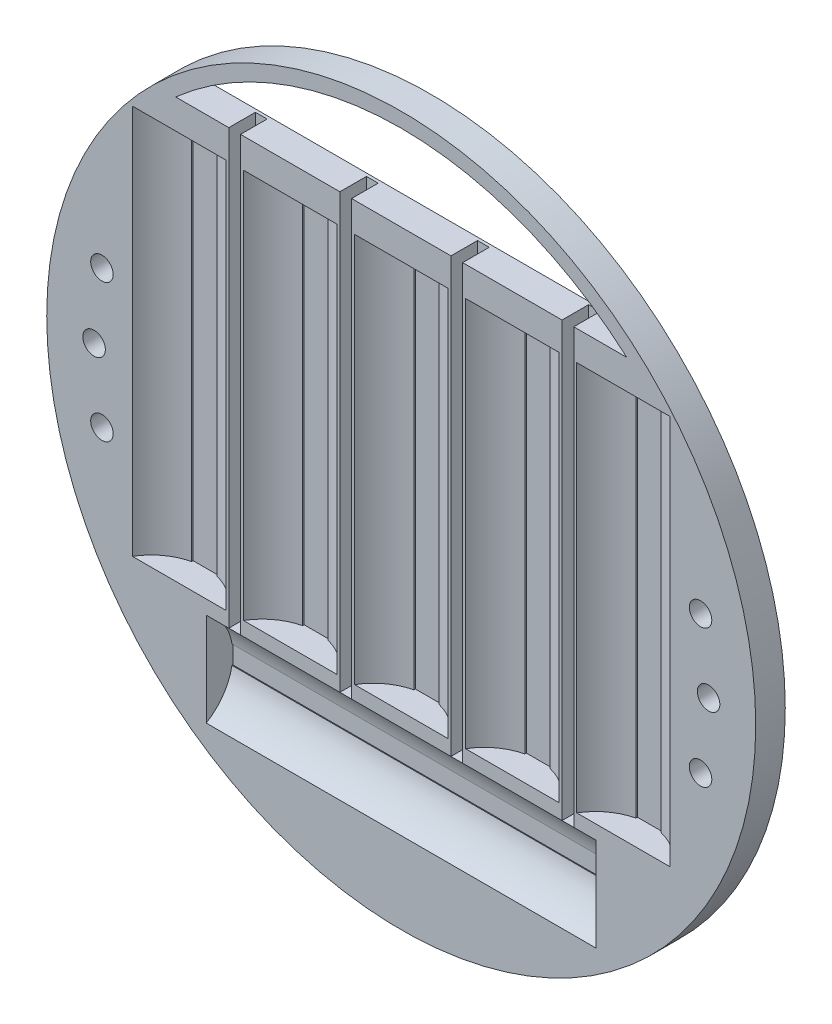
from build123d import *

# Parameters (mm, degrees)
SKETCH1_R               = 60
BOSS_EXTRUDE1_DEPTH     = 5
SKETCH2_W               = 92
SKETCH2_H               = 66
CUT_EXTRUDE1_DEPTH      = 4.5
SKETCH3_W               = 66
SKETCH3_H               = 18.4
CUT_EXTRUDE2_DEPTH      = 4.5
CUT_EXTRUDE3_DEPTH      = 5.5
CUT_EXTRUDE3_DEPTH_BACK = 1.5
BOSS_EXTRUDE4_DEPTH     = 66
BOSS_EXTRUDE5_DEPTH     = 66
LPATTERN1_COUNT         = 5
LPATTERN1_PITCH         = 18.8
SKETCH10_R              = 1.905
CUT_EXTRUDE4_DEPTH      = 6
SKETCH11_W              = 1.982288408
SKETCH11_H              = 73.369538915
CUT_EXTRUDE5_DEPTH      = 4.5
LPATTERN2_COUNT         = 4
LPATTERN2_PITCH         = 18.8
SKETCH12_R              = 1.905
CUT_EXTRUDE6_DEPTH      = 6


with BuildPart() as part:
    # Sketch1 → Boss-Extrude1 (new body)
    with BuildSketch(Plane.XY):
        Circle(SKETCH1_R)
    extrude(amount=BOSS_EXTRUDE1_DEPTH)

    # Sketch2 → Cut-Extrude1 (cut)
    with BuildSketch(Plane.XY.offset(5)):
        with Locations((0, 5)):
            Rectangle(SKETCH2_W, SKETCH2_H)
    extrude(amount=-CUT_EXTRUDE1_DEPTH, mode=Mode.SUBTRACT)

    # Sketch3 → Cut-Extrude2 (cut)
    with BuildSketch(Plane.XY.offset(5)):
        with Locations((0, -38.2)):
            Rectangle(SKETCH3_W, SKETCH3_H)
    extrude(amount=-CUT_EXTRUDE2_DEPTH, mode=Mode.SUBTRACT)

    # Sketch4 → Cut-Extrude3 (cut, two sides)
    with BuildSketch(Plane.XY.offset(0.5)) as cut_extrude3_sk:
        with BuildLine():
            Line((-38.173943993, 43), (38.173943993, 43))
            ThreePointArc((38.173943993, 43), (0, 57.5), (-38.173943993, 43))
        make_face()
    extrude(amount=CUT_EXTRUDE3_DEPTH, mode=Mode.SUBTRACT)
    extrude(cut_extrude3_sk.sketch, amount=-CUT_EXTRUDE3_DEPTH_BACK, mode=Mode.SUBTRACT)

    # Sketch8 → Boss-Extrude4 (add)
    with BuildSketch(Plane(origin=(-33, 0, 0), x_dir=(0, 0, -1), z_dir=(1, 0, 0))):
        with BuildLine():
            Line((-5, -47.4), (-5, -46.187250507))
            ThreePointArc((-5, -46.187250507), (-2.139853595, -43.520930962), (-0.645401314, -39.907579367))
            Line((-0.645401314, -39.907579367), (-0.5, -39.907579367))
            Line((-0.5, -39.907579367), (-0.5, -47.4))
            Line((-0.5, -47.4), (-5, -47.4))
        make_face()
        with BuildLine():
            Line((-5, -29), (-5, -30.369538915))
            ThreePointArc((-5, -30.369538915), (-2.101750406, -33.091237194), (-0.622561202, -36.781696722))
            Line((-0.622561202, -36.781696722), (-0.5, -36.781696722))
            Line((-0.5, -36.781696722), (-0.5, -29))
            Line((-0.5, -29), (-5, -29))
        make_face()
    extrude(amount=BOSS_EXTRUDE4_DEPTH)

    # Sketch9 → Boss-Extrude5 (add)
    with BuildSketch(Plane(origin=(-30.969379717, 38, 37.672222409), x_dir=(0, 0, -1), z_dir=(0, -1, 0))):
        with BuildLine():
            Line((32.672222409, -15.030620283), (32.672222409, -14.530620283))
            ThreePointArc((32.672222409, -14.530620283), (35.383633316, -12.07254318), (36.922222409, -8.751905327))
            Line((36.922222409, -8.751905327), (37.172222409, -8.751905327))
            Line((37.172222409, -8.751905327), (37.172222409, -15.030620283))
            Line((37.172222409, -15.030620283), (32.672222409, -15.030620283))
        make_face()
        with BuildLine():
            Line((32.672222409, 1.787091309), (32.672222409, 1.287091309))
            ThreePointArc((32.672222409, 1.287091309), (35.383633316, -1.170985793), (36.922222409, -4.491623646))
            Line((36.922222409, -4.491623646), (37.172222409, -4.491623646))
            Line((37.172222409, -4.491623646), (37.172222409, 1.787091309))
            Line((37.172222409, 1.787091309), (32.672222409, 1.787091309))
        make_face()
    boss_extrude5 = extrude(amount=BOSS_EXTRUDE5_DEPTH)

    # LPattern1: Boss-Extrude5 ×5
    with Locations(*[(i * LPATTERN1_PITCH, 0, 0) for i in range(1, LPATTERN1_COUNT)]):
        add(boss_extrude5)

    # Sketch10 → Cut-Extrude4 (cut, through all)
    with BuildSketch(Plane(origin=(0, 0, 0), x_dir=(-1, 0, 0), z_dir=(0, 0, -1))):
        with Locations((-52.017711592, 0)):
            Circle(SKETCH10_R)
        with Locations((51.982288408, 0)):
            Circle(SKETCH10_R)
    extrude(amount=-CUT_EXTRUDE4_DEPTH, mode=Mode.SUBTRACT)

    # Sketch11 → Cut-Extrude5 (cut)
    with BuildSketch(Plane.XY.offset(5)):
        with Locations((-28.191144204, 6.315230542)):
            Rectangle(SKETCH11_W, SKETCH11_H)
    cut_extrude5 = extrude(amount=-CUT_EXTRUDE5_DEPTH, mode=Mode.SUBTRACT)

    # LPattern2: Cut-Extrude5 ×4
    with Locations(*[(i * LPATTERN2_PITCH, 0, 0) for i in range(1, LPATTERN2_COUNT)]):
        add(cut_extrude5, mode=Mode.SUBTRACT)

    # Sketch12 → Cut-Extrude6 (cut, through all)
    with BuildSketch(Plane(origin=(0, 0, 0), x_dir=(-1, 0, 0), z_dir=(0, 0, -1))):
        with Locations((-50.654578855, 11.67355769)):
            Circle(SKETCH12_R)
        with Locations((-50.654578855, -11.67355769)):
            Circle(SKETCH12_R)
        with Locations((50.654578855, -11.67355769)):
            Circle(SKETCH12_R)
        with Locations((50.654578855, 11.67355769)):
            Circle(SKETCH12_R)
    extrude(amount=-CUT_EXTRUDE6_DEPTH, mode=Mode.SUBTRACT)


solid = part.part
